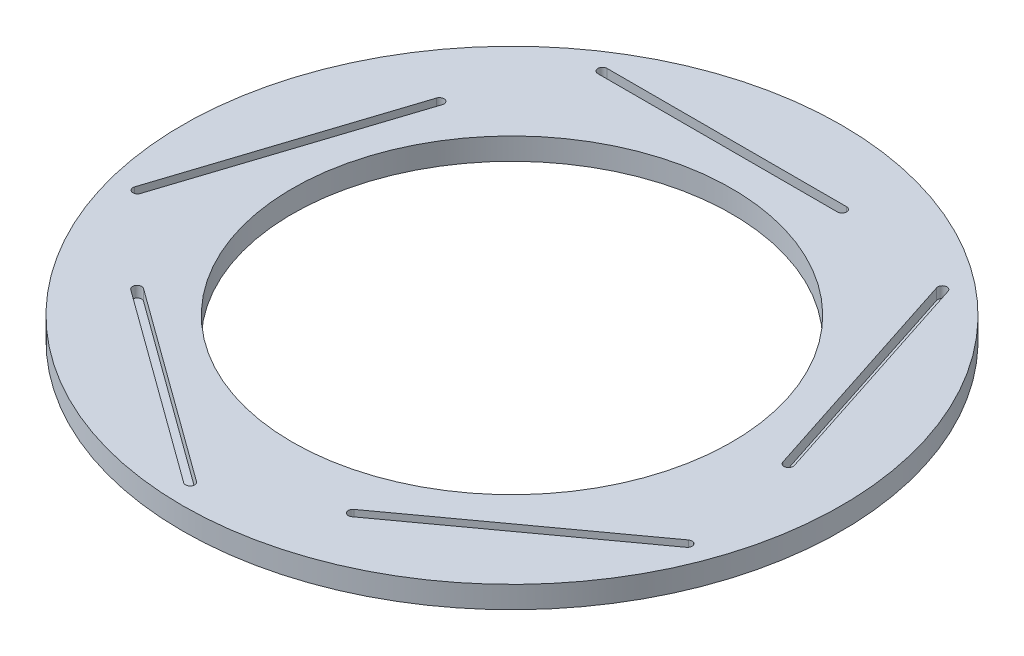
from build123d import *

# Parameters (mm, degrees)
SKETCH1_R           = 45
SKETCH1_R_2         = 30
BOSS_EXTRUDE1_DEPTH = 3
CUT_EXTRUDE1_DEPTH  = 1.5
CIRPATTERN1_COUNT   = 5


with BuildPart() as part:
    # Sketch1 → Boss-Extrude1 (new body)
    with BuildSketch(Plane(origin=(0, 0, 0), x_dir=(1, 0, 0), z_dir=(0, 1, 0))):
        Circle(SKETCH1_R)
        Circle(SKETCH1_R_2, mode=Mode.SUBTRACT)
    extrude(amount=BOSS_EXTRUDE1_DEPTH)

    # Sketch2 → Cut-Extrude1 (cut)
    with BuildSketch(Plane(origin=(0, 3, 0), x_dir=(1, 0, 0), z_dir=(0, 1, 0))):
        with BuildLine():
            Line((10, 34.438191534), (-22.713965574, 34.438191534))
            ThreePointArc((-22.713965574, 34.438191534), (-23.338965574, 35.063191534), (-22.713965574, 35.688191534))
            Line((-22.713965574, 35.688191534), (10, 35.688191534))
            ThreePointArc((10, 35.688191534), (10.625, 35.063191534), (10, 34.438191534))
        make_face()
    cut_extrude1 = extrude(amount=-CUT_EXTRUDE1_DEPTH, mode=Mode.SUBTRACT)

    # CirPattern1: Cut-Extrude1 ×5 about axis
    cirpattern1_axis = Axis((0, 0, 0), (0, 1, 0))
    for i in range(1, CIRPATTERN1_COUNT):
        add(cut_extrude1.rotate(cirpattern1_axis, i * 360 / CIRPATTERN1_COUNT), mode=Mode.SUBTRACT)


solid = part.part
